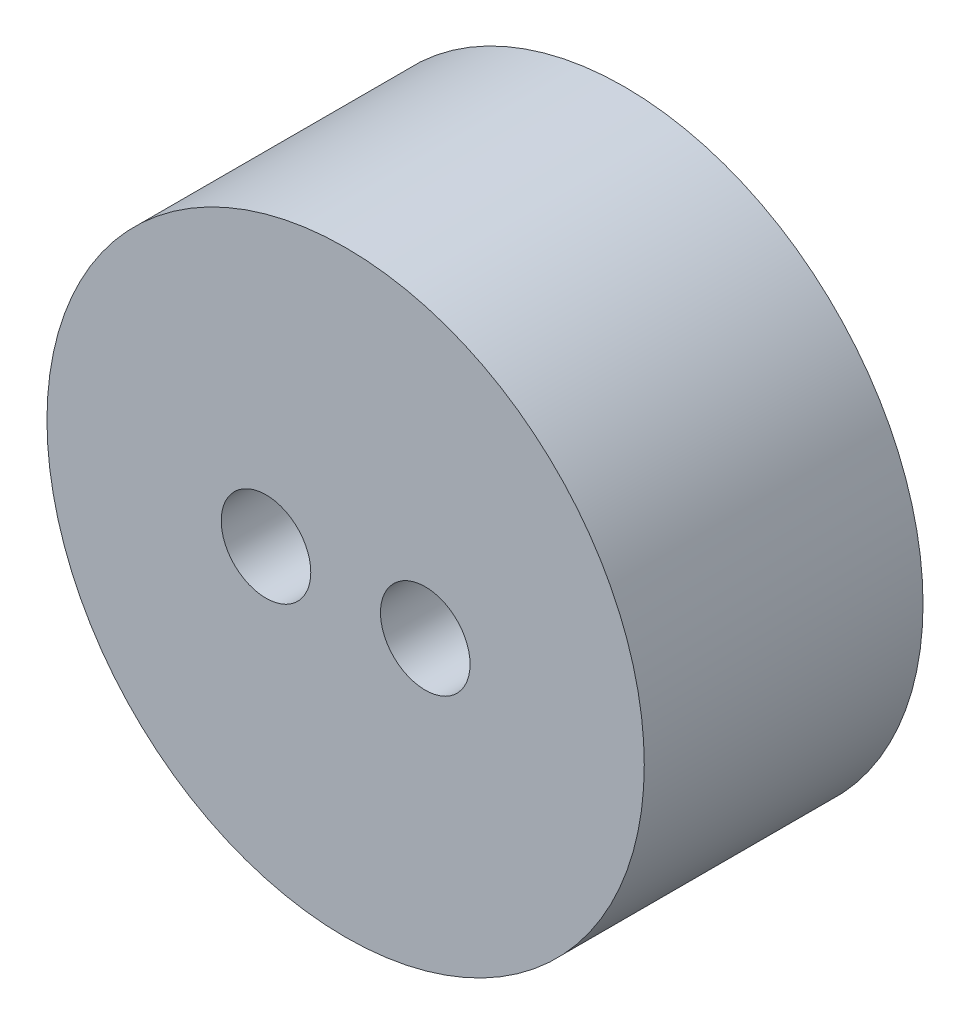
from build123d import *

# Parameters (mm, degrees)
SKETCH_1_R         = 15
EXTRUDE_1_DEPTH    = 14
HOLE_WIZARD_M4_1_D = 4.5


with BuildPart() as part:
    # ｽｹｯﾁ1 → ﾎﾞｽ - 押し出し1 (new body)
    with BuildSketch(Plane.XY):
        Circle(SKETCH_1_R)
    extrude(amount=EXTRUDE_1_DEPTH)

    # M4 すきま穴1 (through all)
    with Locations(Plane.XY.offset(14)):
        with Locations((-4, 0), (4, 0)):
            Hole(HOLE_WIZARD_M4_1_D / 2)


solid = part.part
